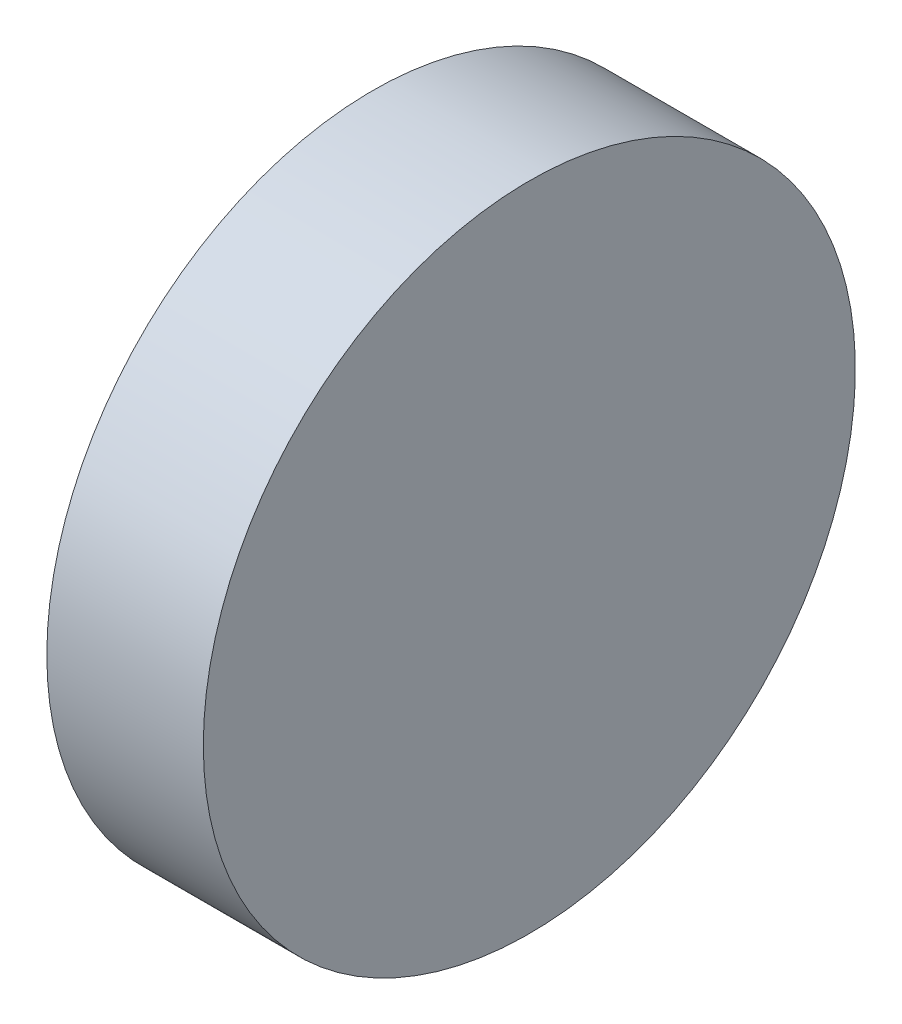
from build123d import *

# Parameters (mm, degrees)
SKETCH_1_W = 6
SKETCH_1_H = 12.5


with BuildPart() as part:
    # 草图1 → 旋转1 (revolve)
    with BuildSketch(Plane.XY, mode=Mode.PRIVATE) as revolve_1_sk:
        with Locations((263.157140493, 83.543179349)):
            Rectangle(SKETCH_1_W, SKETCH_1_H)
    revolve(revolve_1_sk.sketch.rotate(Axis((254.000801993, 77.293179349, 0), (1, 0, 0)), 90), axis=Axis((254.000801993, 77.293179349, 0), (1, 0, 0)))  # turned: the seam where the file's is


solid = part.part
